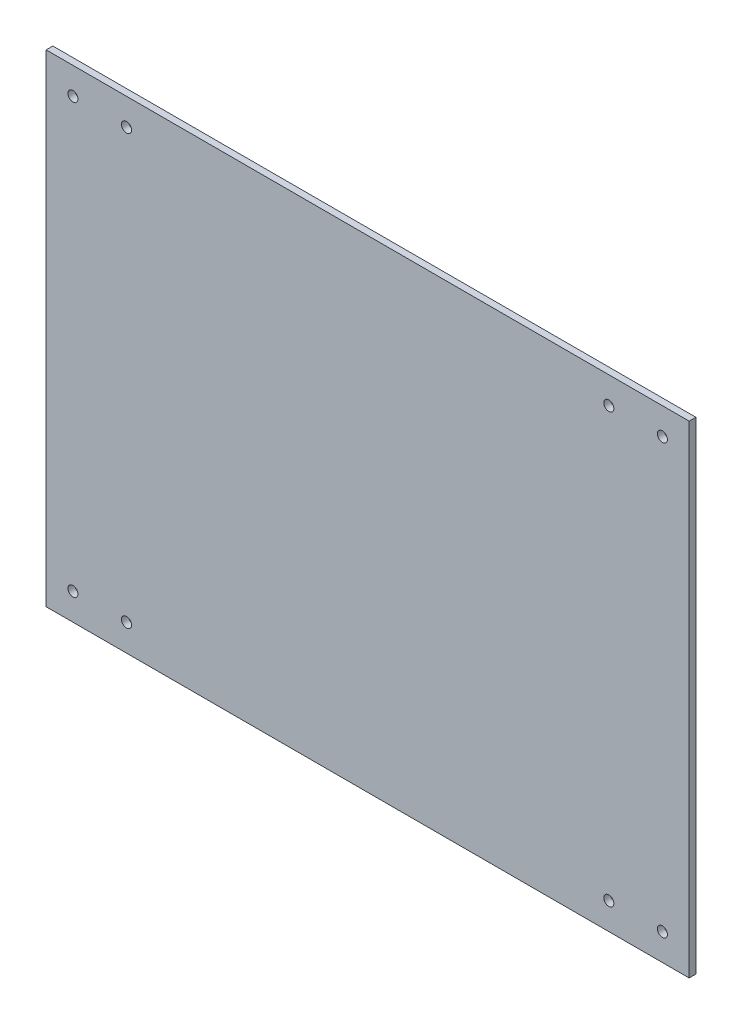
from build123d import *

# Parameters (mm, degrees)
SKETCH1_W           = 304.8
SKETCH1_H           = 228.6
SKETCH1_R           = 2.38125
BOSS_EXTRUDE1_DEPTH = 3.175


with BuildPart() as part:
    # Sketch1 → Boss-Extrude1 (new body)
    with BuildSketch(Plane.XY):
        Rectangle(SKETCH1_W, SKETCH1_H)
        with Locations((139.7, 101.6)):
            Circle(SKETCH1_R, mode=Mode.SUBTRACT)
        with Locations((-139.7, 101.6)):
            Circle(SKETCH1_R, mode=Mode.SUBTRACT)
        with Locations((-139.7, -101.6)):
            Circle(SKETCH1_R, mode=Mode.SUBTRACT)
        with Locations((139.7, -101.6)):
            Circle(SKETCH1_R, mode=Mode.SUBTRACT)
        with Locations((114.3, 101.6)):
            Circle(SKETCH1_R, mode=Mode.SUBTRACT)
        with Locations((-114.3, 101.6)):
            Circle(SKETCH1_R, mode=Mode.SUBTRACT)
        with Locations((-114.3, -101.6)):
            Circle(SKETCH1_R, mode=Mode.SUBTRACT)
        with Locations((114.3, -101.6)):
            Circle(SKETCH1_R, mode=Mode.SUBTRACT)
    extrude(amount=BOSS_EXTRUDE1_DEPTH)


solid = part.part
